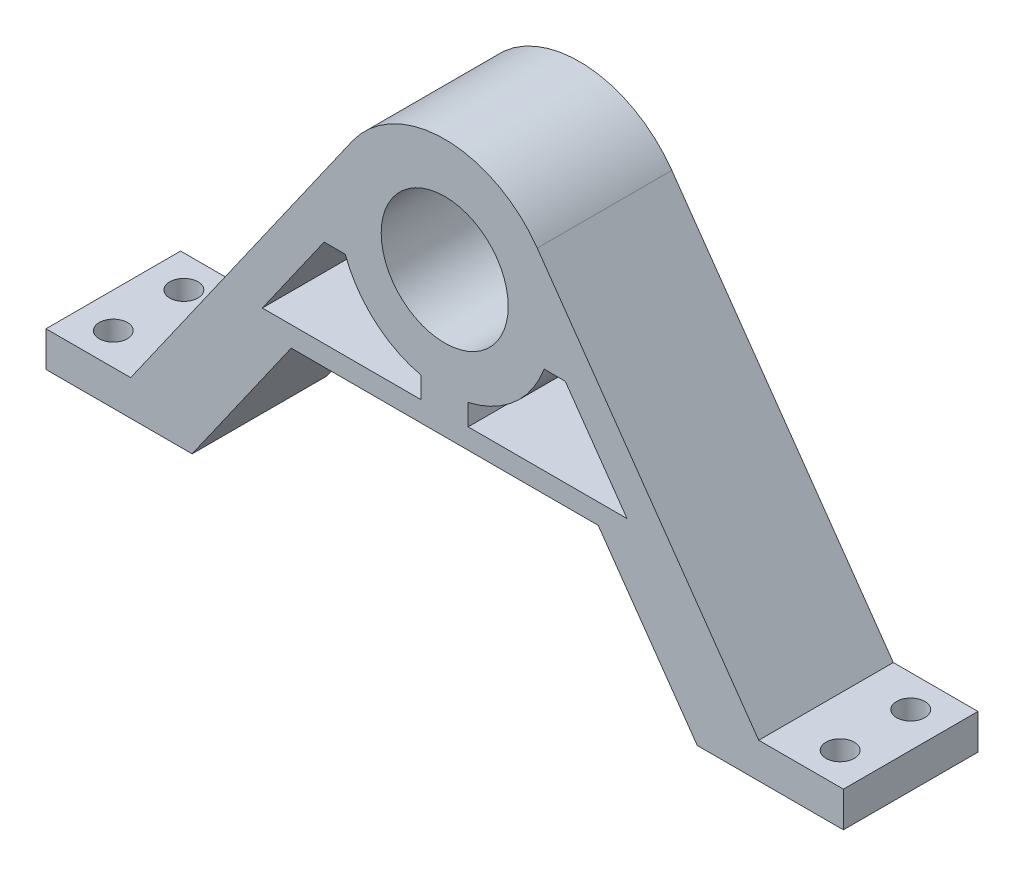
from build123d import *

# Parameters (mm, degrees)
ESQUISSE1_R             = 9
BOSS_EXTRU_1_DEPTH      = 19.075
ESQUISSE2_R             = 11.025
ENL_V_MAT_EXTRU_1_DEPTH = 5.5
ESQUISSE6_R             = 2
ENL_V_MAT_EXTRU_5_DEPTH = 6


with BuildPart() as part:
    # Esquisse1 → Boss.-Extru.1 (new body)
    with BuildSketch(Plane.XY):
        with BuildLine():
            Line((-56.5, 0), (-56.5, 5))
            Line((-56.5, 5), (-44.5, 5))
            Line((-44.5, 5), (-13.11591162, 49.70725189))
            ThreePointArc((-13.11591162, 49.70725189), (0, 56.525), (13.11591162, 49.70725189))
            Line((13.11591162, 49.70725189), (44.5, 5))
            Line((44.5, 5), (56.5, 5))
            Line((56.5, 5), (56.5, 0))
            Line((56.5, 0), (35.791970863, 0))
            Line((35.791970863, 0), (21.7521509, 20))
            Line((21.7521509, 20), (-21.7521509, 20))
            Line((-21.7521509, 20), (-35.791970863, 0))
            Line((-35.791970863, 0), (-56.5, 0))
        make_face()
        with Locations((0, 40.5)):
            Circle(ESQUISSE1_R, mode=Mode.SUBTRACT)
        with BuildLine():
            Line((-17.087305896, 35.347543053), (-25.844479018, 22.872777501))
            Line((-25.844479018, 22.872777501), (-3.323305878, 22.872777501))
            Line((-3.323305878, 22.872777501), (-3.323305878, 25.872777501))
            ThreePointArc((-3.323305878, 25.872777501), (-9.910860011, 29.240566007), (-14.087305896, 35.347543053))
            Line((-14.087305896, 35.347543053), (-17.087305896, 35.347543053))
        make_face(mode=Mode.SUBTRACT)
        with BuildLine():
            Line((17.087305896, 35.347543053), (25.844479018, 22.872777501))
            Line((25.844479018, 22.872777501), (3.323305878, 22.872777501))
            Line((3.323305878, 22.872777501), (3.323305878, 25.872777501))
            ThreePointArc((3.323305878, 25.872777501), (9.910860011, 29.240566007), (14.087305896, 35.347543053))
            Line((14.087305896, 35.347543053), (17.087305896, 35.347543053))
        make_face(mode=Mode.SUBTRACT)
    extrude(amount=BOSS_EXTRU_1_DEPTH)

    # Esquisse2 → Enlèv. mat.-Extru.1 (cut)
    with BuildSketch(Plane(origin=(0, 0, 0), x_dir=(-1, 0, 0), z_dir=(0, 0, -1))):
        with Locations((0, 40.5)):
            Circle(ESQUISSE2_R)
    extrude(amount=-ENL_V_MAT_EXTRU_1_DEPTH, mode=Mode.SUBTRACT)

    # Esquisse6 → Enlèv. mat.-Extru.5 (cut, through all)
    with BuildSketch(Plane(origin=(0, 5, 0), x_dir=(1, 0, 0), z_dir=(0, 1, 0))):
        with Locations(Location((-51.5, -4.5375, 0), (0, 0, 180))):  # turned: the seam where the file's is
            Circle(ESQUISSE6_R)
        with Locations((51.5, -4.5375)):
            Circle(ESQUISSE6_R)
        with Locations(Location((51.5, -14.5375, 0), (0, 0, 180))):  # turned: the seam where the file's is
            Circle(ESQUISSE6_R)
        with Locations((-51.5, -14.5375)):
            Circle(ESQUISSE6_R)
    extrude(amount=-ENL_V_MAT_EXTRU_5_DEPTH, mode=Mode.SUBTRACT)


solid = part.part
